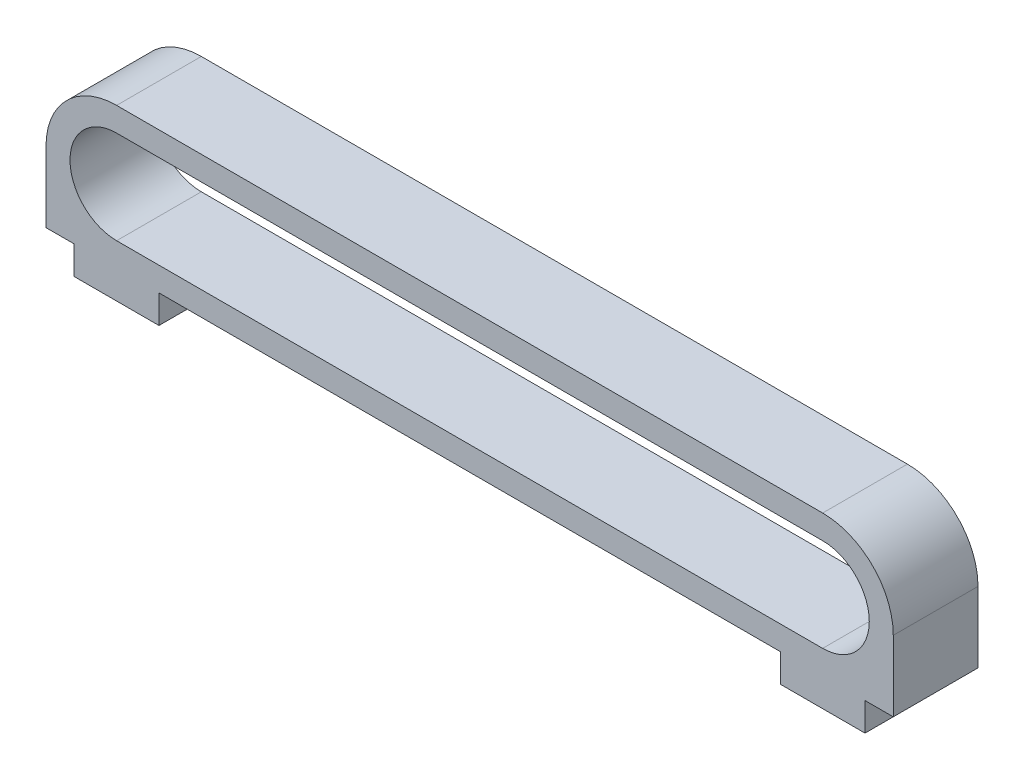
from build123d import *

# Parameters (mm, degrees)
BOSS_EXTRUDE1_DEPTH = 1.5
BOSS_EXTRUDE2_DEPTH = 3
SKETCH3_W           = 3
SKETCH3_H           = 3
BOSS_EXTRUDE3_DEPTH = 1


with BuildPart() as part:
    # Sketch1 → Boss-Extrude1 (new body, symmetric)
    with BuildSketch(Plane.XY):
        with BuildLine():
            Line((-12.5, 2.5), (12.5, 2.5))
            ThreePointArc((12.5, 2.5), (15, 0), (12.5, -2.5))
            Line((12.5, -2.5), (-12.5, -2.5))
            ThreePointArc((-12.5, -2.5), (-15, 0), (-12.5, 2.5))
        make_face()
        with BuildLine():
            Line((-12.5, 1.65), (12.5, 1.65))
            ThreePointArc((12.5, 1.65), (14.15, 0), (12.5, -1.65))
            Line((12.5, -1.65), (-12.5, -1.65))
            ThreePointArc((-12.5, -1.65), (-14.15, 0), (-12.5, 1.65))
        make_face(mode=Mode.SUBTRACT)
    extrude(amount=BOSS_EXTRUDE1_DEPTH, both=True)

    # Sketch2 → Boss-Extrude2 (add)
    with BuildSketch(Plane.XY.offset(1.5)):
        with BuildLine():
            Line((-15, 0), (-15, -2.5))
            Line((-15, -2.5), (-12.5, -2.5))
            ThreePointArc((-12.5, -2.5), (-14.267766953, -1.767766953), (-15, 0))
        make_face()
        with BuildLine():
            Line((12.5, -2.5), (15, -2.5))
            Line((15, -2.5), (15, 0))
            ThreePointArc((15, 0), (14.267766953, -1.767766953), (12.5, -2.5))
        make_face()
    extrude(amount=-BOSS_EXTRUDE2_DEPTH)

    # Sketch3 → Boss-Extrude3 (add)
    with BuildSketch(Plane.XZ.offset(2.5)):
        with Locations((-12.5, 0)):
            Rectangle(SKETCH3_W, SKETCH3_H)
        with Locations((12.5, 0)):
            Rectangle(SKETCH3_W, SKETCH3_H)
    extrude(amount=BOSS_EXTRUDE3_DEPTH)


solid = part.part
